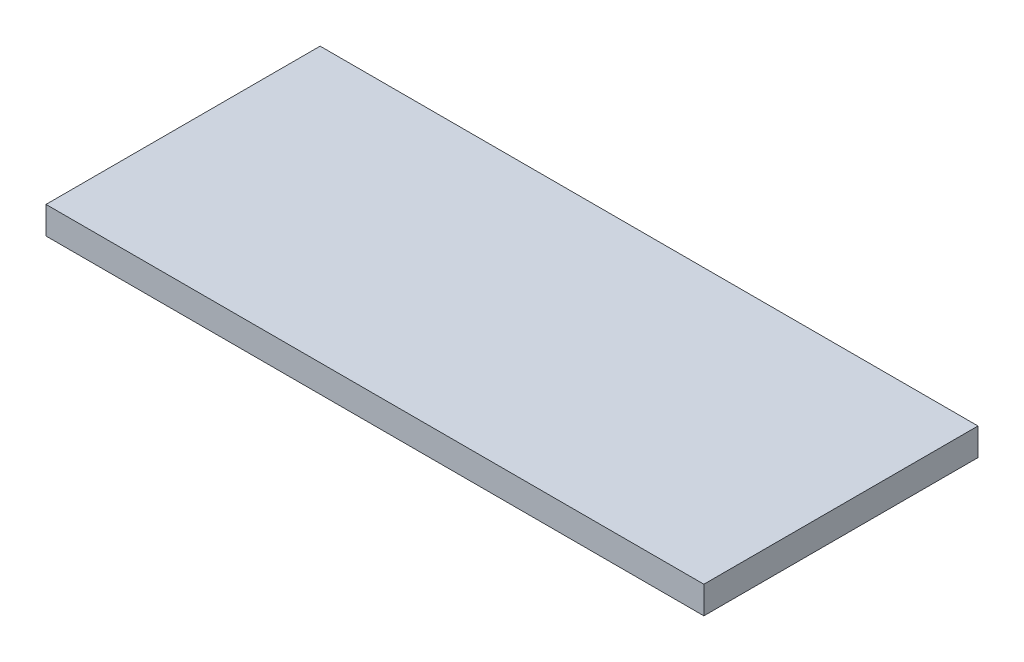
from build123d import *

# Parameters (mm, degrees)
SKETCH1_W           = 120
SKETCH1_H           = 50
BOSS_EXTRUDE1_DEPTH = 5


with BuildPart() as part:
    # Sketch1 → Boss-Extrude1 (new body)
    with BuildSketch(Plane(origin=(0, 0, 0), x_dir=(1, 0, 0), z_dir=(0, 1, 0))):
        with Locations((-6.208530806, -14.218009479)):
            Rectangle(SKETCH1_W, SKETCH1_H)
    extrude(amount=BOSS_EXTRUDE1_DEPTH)


solid = part.part
